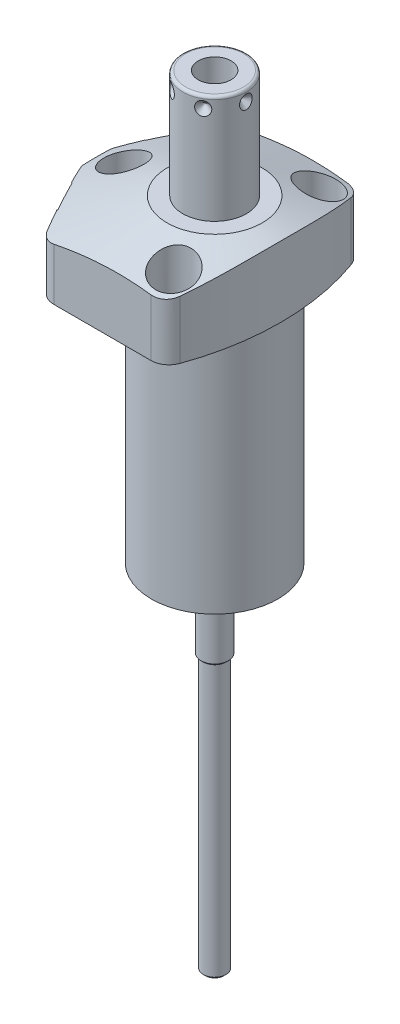
from build123d import *
from build123d.topology import SkipClean

# Parameters (mm, degrees)
CUT_EXTRUDE1_REACH = 28.975
CUT_EXTRUDE2_REACH = 28.975
S2D0002_OUTSIDE_W  = 122.011
S2D0002_OUTSIDE_H  = 101.742
CUT_EXTRUDE3_DEPTH = 38.0873
FILLET1_R          = 6.35
FILLET2_R          = 6.35
FILLET3_R          = 6.35
SKETCH17_R         = 10.4775
CUT_EXTRUDE4_DEPTH = 0.254
SKETCH18_R         = 5.5626
CUT_EXTRUDE5_DEPTH = 2.667
CIRPATTERN1_COUNT  = 6
HOLE1_D            = 8.7376
HOLE1_DEPTH        = 26.9748
HOLE1_CBORE_D      = 13.9954
HOLE1_CBORE_DEPTH  = 16.6624
SKETCH21_R         = 20.7772
EXTRUDE1_DEPTH     = 1.016
SKETCH22_R         = 21.0312
SKETCH22_R_2       = 20.7772
CUT_EXTRUDE6_DEPTH = 1.524
CUT_EXTRUDE7_DEPTH = 1.524
CHAMFER1_SIZE      = 0.762


with BuildPart() as part:
    # Sketch1 → Revolve1 (revolve)
    with BuildSketch(Plane(origin=(0, 0, 0), x_dir=(0, -1, 0), z_dir=(0, 0, 1)), mode=Mode.PRIVATE) as revolve1_sk:
        Polygon((0, 44.45), (-26.9748, 44.45), (-26.9748, 0), (84.1502, 0), (84.1502, 22.098), (0, 22.098), align=None)
    revolve(revolve1_sk.sketch.rotate(Axis((0, 32.53105, 0), (0, -1, 0)), 90), axis=Axis((0, 32.53105, 0), (0, -1, 0)))  # turned: the seam where the file's is

    # Sketch2 → Cut-Extrude1 (cut, up to next)
    with BuildSketch(Plane(origin=(0, 0, 0), x_dir=(0, 0, -1), z_dir=(0, -1, 0)), mode=Mode.PRIVATE) as cut_extrude1_sk1:
        with BuildLine():
            Line((34.1122, -28.498426468), (34.1122, 28.498426468))
            ThreePointArc((34.1122, 28.498426468), (44.45, 0), (34.1122, -28.498426468))
        make_face()
    cut_extrude1_tool1 = extrude(cut_extrude1_sk1.sketch, amount=-CUT_EXTRUDE1_REACH, mode=Mode.PRIVATE) & part.part
    add(cut_extrude1_tool1.solids().sort_by_distance((0, 0, -38.291522))[0], mode=Mode.SUBTRACT)
    # Sketch2 → Cut-Extrude1 (cut, up to next)
    with BuildSketch(Plane(origin=(0, 0, 0), x_dir=(0, 0, -1), z_dir=(0, -1, 0)), mode=Mode.PRIVATE) as cut_extrude1_sk2:
        with BuildLine():
            Line((-34.1122, 28.498426468), (-34.1122, -28.498426468))
            ThreePointArc((-34.1122, -28.498426468), (-44.45, 0), (-34.1122, 28.498426468))
        make_face()
    cut_extrude1_tool2 = extrude(cut_extrude1_sk2.sketch, amount=-CUT_EXTRUDE1_REACH, mode=Mode.PRIVATE) & part.part
    add(cut_extrude1_tool2.solids().sort_by_distance((0, 0, 38.291522))[0], mode=Mode.SUBTRACT)

    # Sketch3 → Cut-Extrude2 (cut, up to next)
    with BuildSketch(Plane(origin=(0, 0, 0), x_dir=(-1, 0, 0), z_dir=(0, -1, 0)), mode=Mode.PRIVATE) as cut_extrude2_sk1:
        with BuildLine():
            Line((25.904926114, 34.1122), (44.042704589, 0))
            Line((44.042704589, 0), (25.904926114, -34.1122))
            Line((25.904926114, -34.1122), (28.498426468, -34.1122))
            ThreePointArc((28.498426468, -34.1122), (44.45, 0), (28.498426468, 34.1122))
            Line((28.498426468, 34.1122), (25.904926114, 34.1122))
        make_face()
    cut_extrude2_tool1 = extrude(cut_extrude2_sk1.sketch, amount=-CUT_EXTRUDE2_REACH, mode=Mode.PRIVATE) & part.part
    add(cut_extrude2_tool1.solids().sort_by_distance((-27.201676, 0, -33.4052))[0], mode=Mode.SUBTRACT)

    # S2D0002 outside → Cut-Extrude3 (cut)
    with BuildSketch(Plane(origin=(0, 0, 0), x_dir=(-1, 0, 0), z_dir=(0, -1, 0))):
        with Locations((-0.2035, 0)):
            Rectangle(S2D0002_OUTSIDE_W, S2D0002_OUTSIDE_H)
        with BuildLine():
            Line((41.275, 85.424995881), (41.275, -85.424995881))
            ThreePointArc((41.275, -85.424995881), (-23.0124, 0), (41.275, 85.424995881))
        make_face(mode=Mode.SUBTRACT)
    extrude(amount=-CUT_EXTRUDE3_DEPTH, mode=Mode.SUBTRACT)

    # Fillet1
    fillet1_edges = [part.edges().sort_by_distance(p)[0] for p in [
        (16.207270797, 13.4874, 34.1122),
        (16.207270797, 13.4874, -34.1122),
    ]]
    fillet(fillet1_edges, radius=FILLET1_R)

    # Fillet2
    fillet2_edges = [part.edges().sort_by_distance(p)[0] for p in [
        (-25.904926114, 13.4874, 34.1122),
    ]]
    fillet(fillet2_edges, radius=FILLET2_R)

    # Fillet3
    fillet3_edges = [part.edges().sort_by_distance(p)[0] for p in [
        (-25.904926114, 13.4874, -34.1122),
    ]]
    fillet(fillet3_edges, radius=FILLET3_R)

    # Sketch5 → Cut-Revolve1 (revolve, cut)
    with BuildSketch(Plane.XY, mode=Mode.PRIVATE) as cut_revolve1_sk:
        Polygon((-16.637, 26.9748), (-47.625, 15.696090381), (-47.625, 26.9748), align=None)
    revolve(cut_revolve1_sk.sketch.rotate(Axis((0, 7.66490951, 0), (0, 1, 0)), 90), axis=Axis((0, 7.66490951, 0), (0, 1, 0)), mode=Mode.SUBTRACT)  # turned: the seam where the file's is

    # Sketch6 → Cut-Revolve2 (revolve, cut)
    with BuildSketch(Plane(origin=(-34.111267534, 10.287, -18.137282674), x_dir=(0.469471563, 0, -0.882947593), z_dir=(0, 1, 0))):
        Polygon((0, 0), (6.1849, 0), (5.642306865, -2.5527), (4.9784, -3.216606865), (4.9784, -15.748), (0, -15.748), align=None)
    revolve(axis=Axis((-19.511375907, 10.287, -10.374382594), (-0.882947593, 0, -0.469471563)), mode=Mode.SUBTRACT)

    # Sketch7 → Cut-Revolve3 (revolve, cut)
    with BuildSketch(Plane(origin=(-34.111267534, 10.287, 18.137282674), x_dir=(-0.469471563, 0, -0.882947593), z_dir=(0, 1, 0))):
        Polygon((0, 0), (6.1849, 0), (5.642306865, -2.5527), (4.9784, -3.216606865), (4.9784, -15.748), (0, -15.748), align=None)
    revolve(axis=Axis((-19.511375907, 10.287, 10.374382594), (-0.882947593, 0, 0.469471563)), mode=Mode.SUBTRACT)

    # Sketch8 → Cut-Revolve4 (revolve, cut)
    with BuildSketch(Plane(origin=(-13.4874, 2.667, -26.5938), x_dir=(-1, 0, 0), z_dir=(0, 0, 1)), mode=Mode.PRIVATE) as cut_revolve4_sk:
        Polygon((0, 0), (4.5466, 0), (4.106586662, -2.0701), (3.4544, -2.722286662), (3.4544, -12.573), (0, -12.573), align=None)
    revolve(cut_revolve4_sk.sketch.rotate(Axis((-13.4874, 15.86865, -26.5938), (0, -1, 0)), 270), axis=Axis((-13.4874, 15.86865, -26.5938), (0, -1, 0)), mode=Mode.SUBTRACT)  # turned: the seam where the file's is

    # Sketch9 → Cut-Revolve5 (revolve, cut)
    with BuildSketch(Plane(origin=(-13.4874, 2.667, 26.5938), x_dir=(-1, 0, 0), z_dir=(0, 0, 1)), mode=Mode.PRIVATE) as cut_revolve5_sk:
        Polygon((0, 0), (4.5466, 0), (4.106586662, -2.0701), (3.4544, -2.722286662), (3.4544, -12.573), (0, -12.573), align=None)
    revolve(cut_revolve5_sk.sketch.rotate(Axis((-13.4874, 15.86865, 26.5938), (0, -1, 0)), 270), axis=Axis((-13.4874, 15.86865, 26.5938), (0, -1, 0)), mode=Mode.SUBTRACT)  # turned: the seam where the file's is

    # Sketch17 → Cut-Extrude4 (cut)
    with BuildSketch(Plane(origin=(-34.335536223, 0, 18.256528451), x_dir=(0.469471563, 0, 0.882947593), z_dir=(-0.882947593, 0, 0.469471563))):
        with Locations((0, 10.287)):
            Circle(SKETCH17_R)
    cut_extrude4 = extrude(amount=-CUT_EXTRUDE4_DEPTH, mode=Mode.SUBTRACT)

    # Sketch18 → Cut-Extrude5 (cut)
    with BuildSketch(Plane.XZ):
        with Locations(Location((-13.4874, 26.5938, 0), (0, 0, 270))):  # turned: the seam where the file's is
            Circle(SKETCH18_R)
    cut_extrude5 = extrude(amount=-CUT_EXTRUDE5_DEPTH, mode=Mode.SUBTRACT)

    # Mirror1: Cut-Extrude4, Cut-Extrude5 across plane
    add(cut_extrude4.mirror(Plane.XY), mode=Mode.SUBTRACT)
    add(cut_extrude5.mirror(Plane.XY), mode=Mode.SUBTRACT)

    # Sketch10 → Revolve2 (revolve)
    with BuildSketch(Plane(origin=(0, 0, 0), x_dir=(0, 0, -1), z_dir=(1, 0, 0)), mode=Mode.PRIVATE) as revolve2_sk:
        with BuildLine():
            Line((0, 26.9748), (-11.1125, 26.9748))
            Line((-11.1125, 26.9748), (-11.1125, 63.8302))
            ThreePointArc((-11.1125, 63.8302), (-10.81492049, 64.54862049), (-10.0965, 64.8462))
            Line((-10.0965, 64.8462), (0, 64.8462))
            Line((0, 64.8462), (0, 26.9748))
        make_face()
    revolve(revolve2_sk.sketch.rotate(Axis((0, 14.351681477, 0), (0, 1, 0)), 180), axis=Axis((0, 14.351681477, 0), (0, 1, 0)))  # turned: the seam where the file's is

    # S2D0001 → Cut-Revolve6 (revolve, cut)
    with BuildSketch(Plane(origin=(5.7531, 64.8462, 0), x_dir=(1, 0, 0), z_dir=(0, 0, 1)), mode=Mode.PRIVATE) as cut_revolve6_sk:
        Polygon((0, 0), (0, -17.018), (-5.7531, -20.474811227), (-5.7531, 0), align=None)
    revolve(cut_revolve6_sk.sketch.rotate(Axis((0, 37.109882775, 0), (0, 1, 0)), 90), axis=Axis((0, 37.109882775, 0), (0, 1, 0)), mode=Mode.SUBTRACT)  # turned: the seam where the file's is

    # Sketch14 → Revolve3 (revolve)
    with BuildSketch(Plane(origin=(-13.4874, 0, 26.5938), x_dir=(0, 0, -1), z_dir=(1, 0, 0))):
        with BuildLine():
            Line((5.461, 2.667), (5.461, 0.9398))
            Line((5.461, 0.9398), (5.301559456, 0.9398))
            ThreePointArc((5.301559456, 0.9398), (4.572, -0.4572), (3.842440544, 0.9398))
            Line((3.842440544, 0.9398), (3.175, 0.9398))
            ThreePointArc((3.175, 0.9398), (2.815789755, 0.791010245), (2.667, 0.4318))
            Line((2.667, 0.4318), (2.667, 0.127))
            Line((2.667, 0.127), (1.5875, 0.127))
            Line((1.5875, 0.127), (1.5875, 10.6172))
            Line((1.5875, 10.6172), (3.2512, 10.6172))
            Line((3.2512, 10.6172), (3.2512, 2.667))
            Line((3.2512, 2.667), (5.461, 2.667))
        make_face()
    revolve3 = revolve(axis=Axis((-13.4874, -1.01092, 26.5938), (0, 1, 0)))

    # Sketch15 → Cut-Revolve7 (revolve, cut)
    with BuildSketch(Plane(origin=(-11.1125, 60.8838, 0), x_dir=(0, 1, 0), z_dir=(0, 0, 1)), mode=Mode.PRIVATE) as cut_revolve7_sk:
        Polygon((0, 0), (2.413, 0), (0, -2.413), align=None)
    cut_revolve7 = revolve(cut_revolve7_sk.sketch.rotate(Axis((-6.003069898, 60.8838, 0), (-1, 0, 0)), 270), axis=Axis((-6.003069898, 60.8838, 0), (-1, 0, 0)), mode=Mode.SUBTRACT)  # turned: the seam where the file's is

    # CirPattern1: Cut-Revolve7 ×6 about axis
    cirpattern1_axis = Axis((0, 14.351681477, 0), (0, -1, 0))
    for i in range(1, CIRPATTERN1_COUNT):
        add(cut_revolve7.rotate(cirpattern1_axis, i * 360 / CIRPATTERN1_COUNT), mode=Mode.SUBTRACT)

    # Hole1
    with Locations(Plane(origin=(0, 26.9748, 0), x_dir=(-1, 0, 0), z_dir=(0, 1, 0))):
        with Locations((-11.1252, -25.4), (31.75, 0), (-11.1252, 25.4)):
            CounterBoreHole(HOLE1_D / 2, HOLE1_CBORE_D / 2, HOLE1_CBORE_DEPTH, depth=HOLE1_DEPTH)

    # Mirror2: Revolve3 across plane
    add(revolve3.mirror(Plane.XY))

    # Sketch21 → Extrude1 (add)
    with BuildSketch(Plane.XZ.offset(84.1502)):
        with Locations(Location((0, 0, 0), (0, 0, 90))):  # turned: the seam where the file's is
            Circle(SKETCH21_R)
    extrude(amount=EXTRUDE1_DEPTH)

    # Sketch22 → Cut-Extrude6 (cut)
    with SkipClean():  # keep this step's faces unmerged: merging them makes the solid invalid here
        with BuildSketch(Plane.XZ.offset(84.1502)):
            with Locations(Location((0, 0, 0), (0, 0, 270))):  # turned: the seam where the file's is
                Circle(SKETCH22_R)
            with Locations(Location((0, 0, 0), (0, 0, 270))):  # turned: the seam where the file's is
                Circle(SKETCH22_R_2, mode=Mode.SUBTRACT)
        extrude(amount=-CUT_EXTRUDE6_DEPTH, mode=Mode.SUBTRACT)

    # Sketch31 → Cut-Extrude7 (cut)
    with BuildSketch(Plane.XZ.offset(85.1662)):
        with BuildLine():
            Line((-1.1938, 8.642842216), (-1.1938, 20.742875437))
            ThreePointArc((-1.1938, 20.742875437), (0, 20.7772), (1.1938, 20.742875437))
            Line((1.1938, 20.742875437), (1.1938, 8.642842216))
            ThreePointArc((1.1938, 8.642842216), (8.7249, 0), (1.1938, -8.642842216))
            Line((1.1938, -8.642842216), (1.1938, -20.742875437))
            ThreePointArc((1.1938, -20.742875437), (0, -20.7772), (-1.1938, -20.742875437))
            Line((-1.1938, -20.742875437), (-1.1938, -8.642842216))
            ThreePointArc((-1.1938, -8.642842216), (-8.7249, 0), (-1.1938, 8.642842216))
        make_face()
    extrude(amount=-CUT_EXTRUDE7_DEPTH, mode=Mode.SUBTRACT)

    # Sketch32 → Revolve4 (revolve)
    with BuildSketch(Plane.XY, mode=Mode.PRIVATE) as revolve4_sk:
        Polygon((4.7625, -83.6422), (4.7625, -111.4806), (3.9624, -112.2807), (3.9624, -207.6196), (0, -207.6196), (0, -83.6422), align=None)
    revolve(revolve4_sk.sketch.rotate(Axis((0, 0, 0), (0, -1, 0)), 86.706130152), axis=Axis((0, 0, 0), (0, -1, 0)))  # turned: the seam where the file's is

    # Chamfer1
    chamfer1_edges = [part.edges().sort_by_distance(p)[0] for p in [
        (20.7772, -85.1662, 0),
        (-20.7772, -85.1662, 0),
        (-0.22766846, -207.6196, -3.955853995),
    ]]
    chamfer(chamfer1_edges, length=CHAMFER1_SIZE)


solid = part.part
